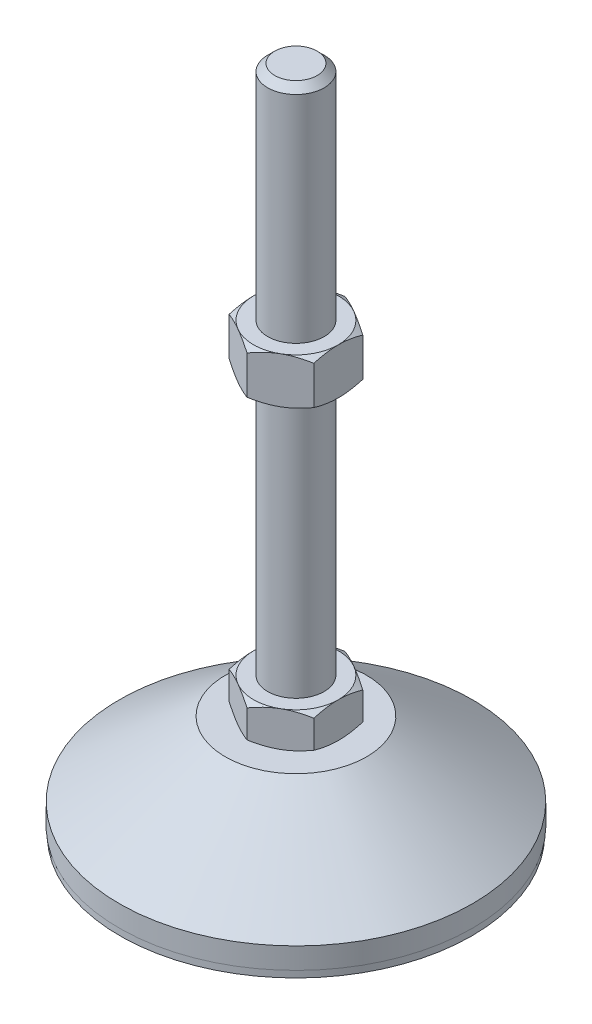
from build123d import *

# Parameters (mm, degrees)
EXTRUDE_1_DEPTH = 10
EXTRUDE_2_DEPTH = 13


with BuildPart() as part:
    # Эскиз1 → Повернуть1 (revolve)
    with BuildSketch(Plane.XY, mode=Mode.PRIVATE) as revolve_1_sk:
        Polygon((0, 0), (-49.8, 0), (-49.8, 2), (-50, 2), (-50, 8), (-20, 29), (-8, 29), (-8, 39), (-8, 187), (-6, 189), (0, 189), align=None)
    revolve(revolve_1_sk.sketch.rotate(Axis((0, 0, 0), (0, 1, 0)), 180), axis=Axis((0, 0, 0), (0, 1, 0)))  # turned: the seam where the file's is

    # Эскиз2 → Бобышка-Вытянуть1 (add)
    with BuildSketch(Plane(origin=(0, 29, 0), x_dir=(1, 0, 0), z_dir=(0, 1, 0))):
        Polygon((0, 13.856406461), (-12, 6.92820323), (-12, -6.92820323), (0, -13.856406461), (12, -6.92820323), (12, 6.92820323), align=None)
    extrude(amount=EXTRUDE_1_DEPTH)

    # Эскиз3 → Бобышка-Вытянуть2 (add)
    with BuildSketch(Plane(origin=(0, 113, 0), x_dir=(1, 0, 0), z_dir=(0, 1, 0))):
        Polygon((12, 6.92820323), (0, 13.856406461), (-12, 6.92820323), (-12, -6.92820323), (0, -13.856406461), (12, -6.92820323), align=None)
    extrude(amount=EXTRUDE_2_DEPTH)

    # Эскиз4 → Вырез-Повернуть2 (revolve, cut)
    with BuildSketch(Plane.XY, mode=Mode.PRIVATE) as cut_revolve_2_sk:
        Polygon((-23.258330249, 126), (-12, 126), (-23.258330249, 119.5), align=None)
        Polygon((-23.258330249, 113), (-23.258330249, 119.5), (-12, 113), align=None)
        Polygon((-20.660254038, 39), (-20.660254038, 34), (-12, 39), align=None)
        Polygon((-20.660254038, 34), (-20.660254038, 29), (-12, 29), align=None)
    revolve(cut_revolve_2_sk.sketch.rotate(Axis((0, 189, 0), (0, -1, 0)), 180), axis=Axis((0, 189, 0), (0, -1, 0)), mode=Mode.SUBTRACT)  # turned: the seam where the file's is


solid = part.part
